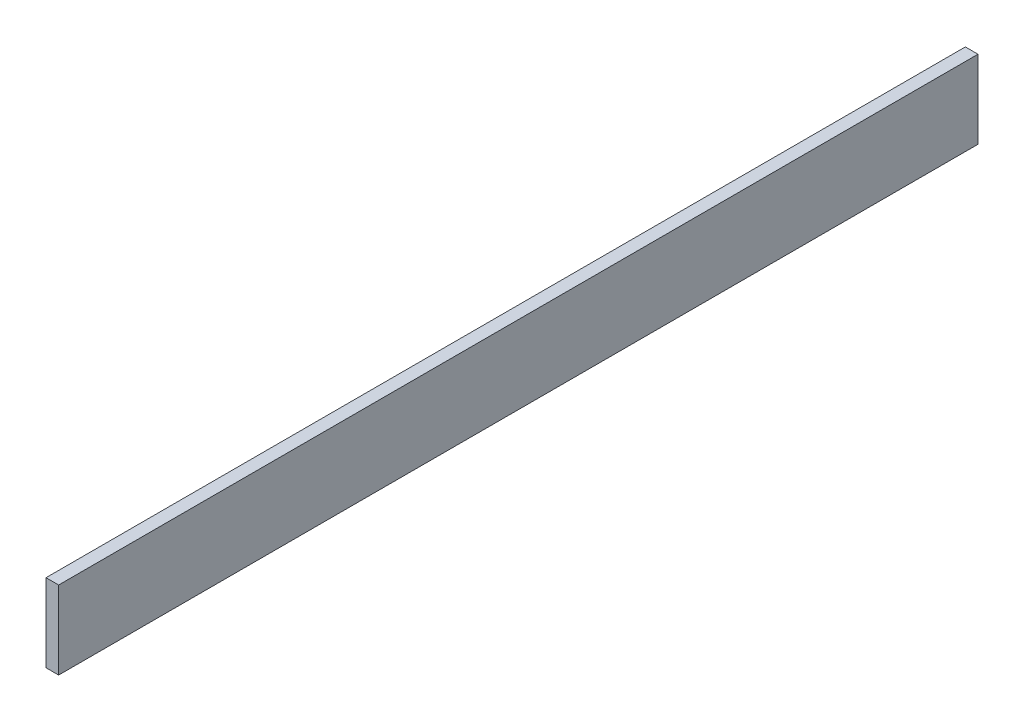
from build123d import *

# Parameters (mm, degrees)
SKETCH1_W           = 2768.6
SKETCH1_H           = 234.95
BOSS_EXTRUDE1_DEPTH = 38.1


with BuildPart() as part:
    # Sketch1 → Boss-Extrude1 (new body)
    with BuildSketch(Plane(origin=(0, 0, 0), x_dir=(0, 0, -1), z_dir=(1, 0, 0))):
        with Locations((968.205858564, 231.961069552)):
            Rectangle(SKETCH1_W, SKETCH1_H)
    extrude(amount=BOSS_EXTRUDE1_DEPTH)


solid = part.part
